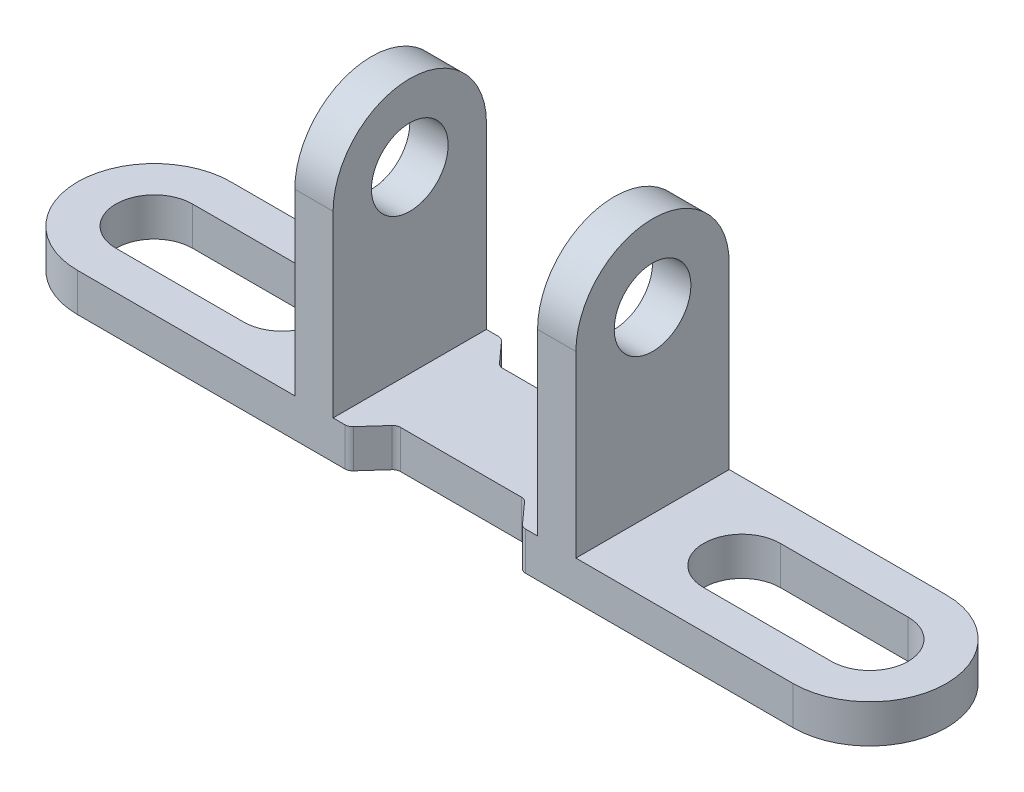
from build123d import *

# Parameters (mm, degrees)
EXTRUDE_1_DEPTH     = 6
CUT_EXTRUDE_1_DEPTH = 12.5
CUT_EXTRUDE_2_DEPTH = 12.5
SKETCH_4_R          = 1.5
CUT_EXTRUDE_3_DEPTH = 23.5
CUT_EXTRUDE_4_DEPTH = 2.5
FILLET_1_R          = 0.3


with BuildPart() as part:
    # 草图1 → 凸台-拉伸1 (new body)
    with BuildSketch(Plane.XY):
        Polygon((-17, 0), (17, 0), (17, 1.5), (5.5, 1.5), (5.5, 11.5), (4, 11.5), (4, 1.5), (-4, 1.5), (-4, 11.5), (-5.5, 11.5), (-5.5, 1.5), (-17, 1.5), align=None)
    extrude(amount=EXTRUDE_1_DEPTH)

    # 草图2 → 切除-拉伸1 (cut, through all)
    with BuildSketch(Plane.XZ):
        with BuildLine():
            Line((-14, 6), (-17, 6))
            Line((-17, 6), (-17, 3))
            ThreePointArc((-17, 3), (-16.121320344, 5.121320344), (-14, 6))
        make_face()
        with BuildLine():
            ThreePointArc((-14, 0), (-16.121320344, 0.878679656), (-17, 3))
            Line((-17, 3), (-17, 0))
            Line((-17, 0), (-14, 0))
        make_face()
        with BuildLine():
            Line((17, 0), (17, 3))
            ThreePointArc((17, 3), (16.121320344, 0.878679656), (14, 0))
            Line((14, 0), (17, 0))
        make_face()
        with BuildLine():
            Line((17, 6), (14, 6))
            ThreePointArc((14, 6), (16.121320344, 5.121320344), (17, 3))
            Line((17, 3), (17, 6))
        make_face()
    extrude(amount=-CUT_EXTRUDE_1_DEPTH, mode=Mode.SUBTRACT)

    # 草图3 → 切除-拉伸2 (cut, through all)
    with BuildSketch(Plane.XZ):
        with BuildLine():
            Line((-9, 1.5), (-14, 1.5))
            ThreePointArc((-14, 1.5), (-15.5, 3), (-14, 4.5))
            Line((-14, 4.5), (-9, 4.5))
            ThreePointArc((-9, 4.5), (-7.5, 3), (-9, 1.5))
        make_face()
        with BuildLine():
            Line((9, 4.5), (14, 4.5))
            ThreePointArc((14, 4.5), (15.5, 3), (14, 1.5))
            Line((14, 1.5), (9, 1.5))
            ThreePointArc((9, 1.5), (7.5, 3), (9, 4.5))
        make_face()
    extrude(amount=-CUT_EXTRUDE_2_DEPTH, mode=Mode.SUBTRACT)

    # 草图4 → 切除-拉伸3 (cut, through all)
    with BuildSketch(Plane(origin=(5.5, 0, 0), x_dir=(0, 0, -1), z_dir=(1, 0, 0))):
        with BuildLine():
            Line((-3, 11.5), (-6, 11.5))
            Line((-6, 11.5), (-6, 8.5))
            ThreePointArc((-6, 8.5), (-5.121320344, 10.621320344), (-3, 11.5))
        make_face()
        with BuildLine():
            Line((0, 11.5), (-3, 11.5))
            ThreePointArc((-3, 11.5), (-0.878679656, 10.621320344), (0, 8.5))
            Line((0, 8.5), (0, 11.5))
        make_face()
        with Locations((-3, 8.5)):
            Circle(SKETCH_4_R)
    extrude(amount=-CUT_EXTRUDE_3_DEPTH, mode=Mode.SUBTRACT)

    # 草图5 → 切除-拉伸4 (cut, through all)
    with BuildSketch(Plane(origin=(0, 1.5, 0), x_dir=(1, 0, 0), z_dir=(0, 1, 0))):
        Polygon((2.5, -1), (3.4, 0), (-3.4, 0), (-2.5, -1), align=None)
        Polygon((-3.4, -6), (3.4, -6), (2.5, -5), (-2.5, -5), align=None)
    extrude(amount=-CUT_EXTRUDE_4_DEPTH, mode=Mode.SUBTRACT)

    # 圆角1
    fillet_1_edges = [part.edges().sort_by_distance(p)[0] for p in [
        (-2.5, 0.75, 1),
        (-3.4, 0.75, 0),
        (3.4, 0.75, 0),
        (2.5, 0.75, 1),
        (-2.5, 0.75, 5),
        (2.5, 0.75, 5),
        (3.4, 0.75, 6),
        (-3.4, 0.75, 6),
    ]]
    fillet(fillet_1_edges, radius=FILLET_1_R)


solid = part.part
